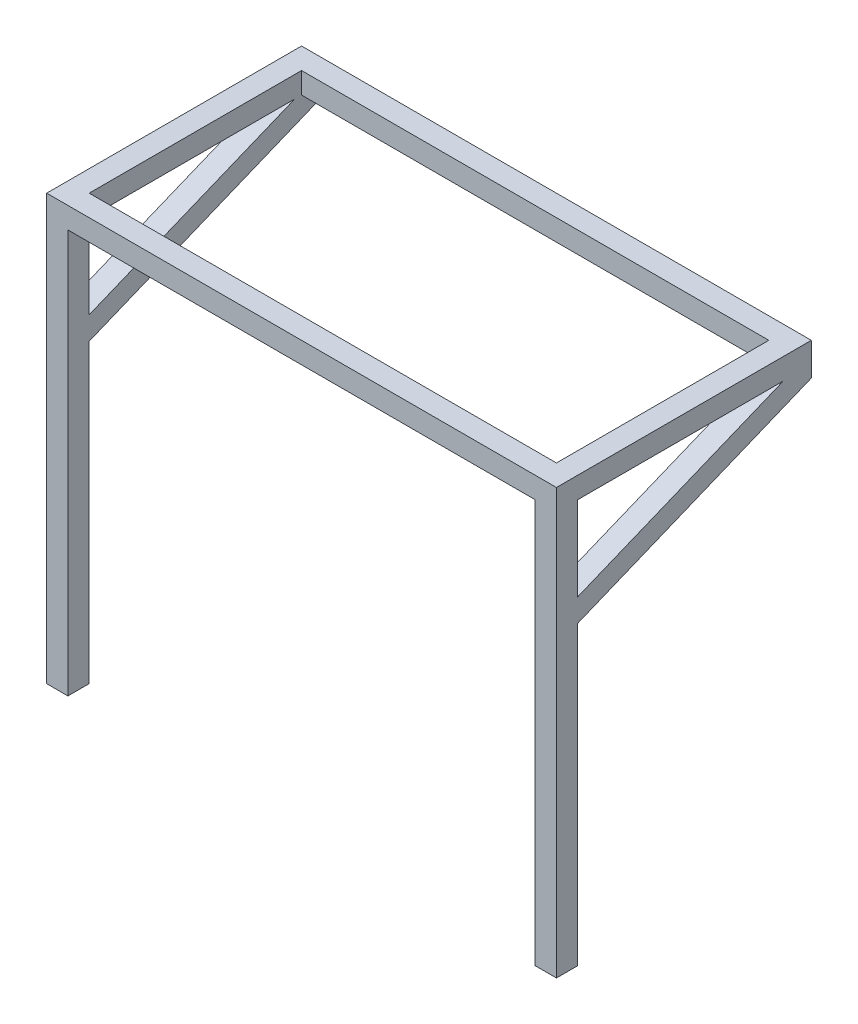
from build123d import *

# Parameters (mm, degrees)
SKETCH1_W             = 25.4
SKETCH1_H             = 25.4
BOSS_EXTRUDE1_DEPTH   = 254
BOSS_EXTRUDE1_2_DEPTH = 254
SKETCH2_W             = 558.8
SKETCH2_H             = 25.4
BOSS_EXTRUDE2_DEPTH   = 25.4
BOSS_EXTRUDE3_DEPTH   = 25.4
BOSS_EXTRUDE4_DEPTH   = 25.4


with BuildPart() as part:
    # Sketch1 → Boss-Extrude1 (new, symmetric)
    with BuildSketch(Plane(origin=(0, 0, 0), x_dir=(1, 0, 0), z_dir=(0, 1, 0))):
        with Locations((12.7, 12.7)):
            Rectangle(SKETCH1_W, SKETCH1_H)
    extrude(amount=BOSS_EXTRUDE1_DEPTH, both=True)



with BuildPart() as body_2:
    # Sketch1 → Boss-Extrude1 2 (new, symmetric)
    with BuildSketch(Plane(origin=(0, 0, 0), x_dir=(1, 0, 0), z_dir=(0, 1, 0))):
        with Locations((596.9, 12.7)):
            Rectangle(SKETCH1_W, SKETCH1_H)
    extrude(amount=BOSS_EXTRUDE1_2_DEPTH, both=True)


with BuildPart() as part_1:
    add(part.part)

    add(body_2.part)  # Boss-Extrude2 merges body 2
    # Sketch2 → Boss-Extrude2 (add)
    with BuildSketch(Plane(origin=(0, 254, 0), x_dir=(1, 0, 0), z_dir=(0, 1, 0))):
        Polygon((0, 304.8), (0, 25.4), (25.4, 25.4), (25.4, 279.4), (584.2, 279.4), (584.2, 25.4), (609.6, 25.4), (609.6, 304.8), align=None)
        with Locations((304.8, 12.7)):
            Rectangle(SKETCH2_W, SKETCH2_H)
    extrude(amount=-BOSS_EXTRUDE2_DEPTH)

    # Sketch3 → Boss-Extrude3 (add)
    with BuildSketch(Plane(origin=(609.6, 0, 0), x_dir=(0, 0, -1), z_dir=(1, 0, 0))):
        Polygon((25.4, 128.021616083), (25.4, 100.578383917), (304.8, 214.878383917), (304.8, 228.6), (271.258271797, 228.6), align=None)
    extrude(amount=-BOSS_EXTRUDE3_DEPTH)

    # Sketch4 → Boss-Extrude4 (add)
    with BuildSketch(Plane.ZY):
        Polygon((-271.258271797, 228.6), (-25.4, 128.021616083), (-25.4, 100.578383917), (-304.8, 214.878383917), (-304.8, 228.6), align=None)
    extrude(amount=-BOSS_EXTRUDE4_DEPTH)


solid = part_1.part
